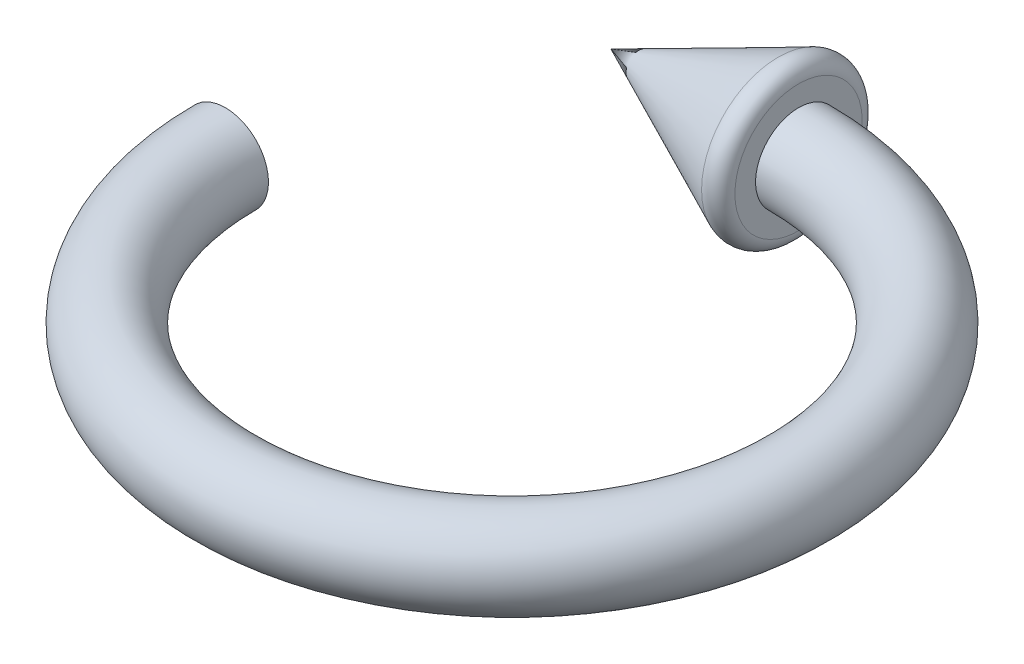
from build123d import *

# Parameters (mm, degrees)
SKETCH2_R = 30
FILLET1_R = 10


with BuildPart() as part:
    # Sweep1: sweep along a path in Sketch1
    with BuildLine(Plane(origin=(0, 0, 0), x_dir=(1, 0, 0), z_dir=(0, 1, 0))) as sweep1_path:
        ThreePointArc((-200, 0), (141.421356237, -141.421356237), (0, 200))
    # Sketch2 → Sweep1 (sweep)
    with BuildSketch(Plane.XY):
        with Locations((-200, 0)):
            Circle(SKETCH2_R)
    sweep(path=sweep1_path.line)

    # Sketch3 → Revolve2 (revolve)
    with BuildSketch(Plane(origin=(0, 0, 0), x_dir=(1, 0, 0), z_dir=(0, 1, 0)), mode=Mode.PRIVATE) as revolve2_sk:
        Polygon((0, 200), (0, 140), (-130.969416576, 200), align=None)
    revolve(revolve2_sk.sketch.rotate(Axis((-130.969416576, 0, -200), (1, 0, 0)), 180), axis=Axis((-130.969416576, 0, -200), (1, 0, 0)))  # turned: the seam where the file's is

    # Fillet1
    fillet1_edges = [part.edges().sort_by_distance(p)[0] for p in [
        (0, 0, -140),
    ]]
    fillet(fillet1_edges, radius=FILLET1_R)


solid = part.part
